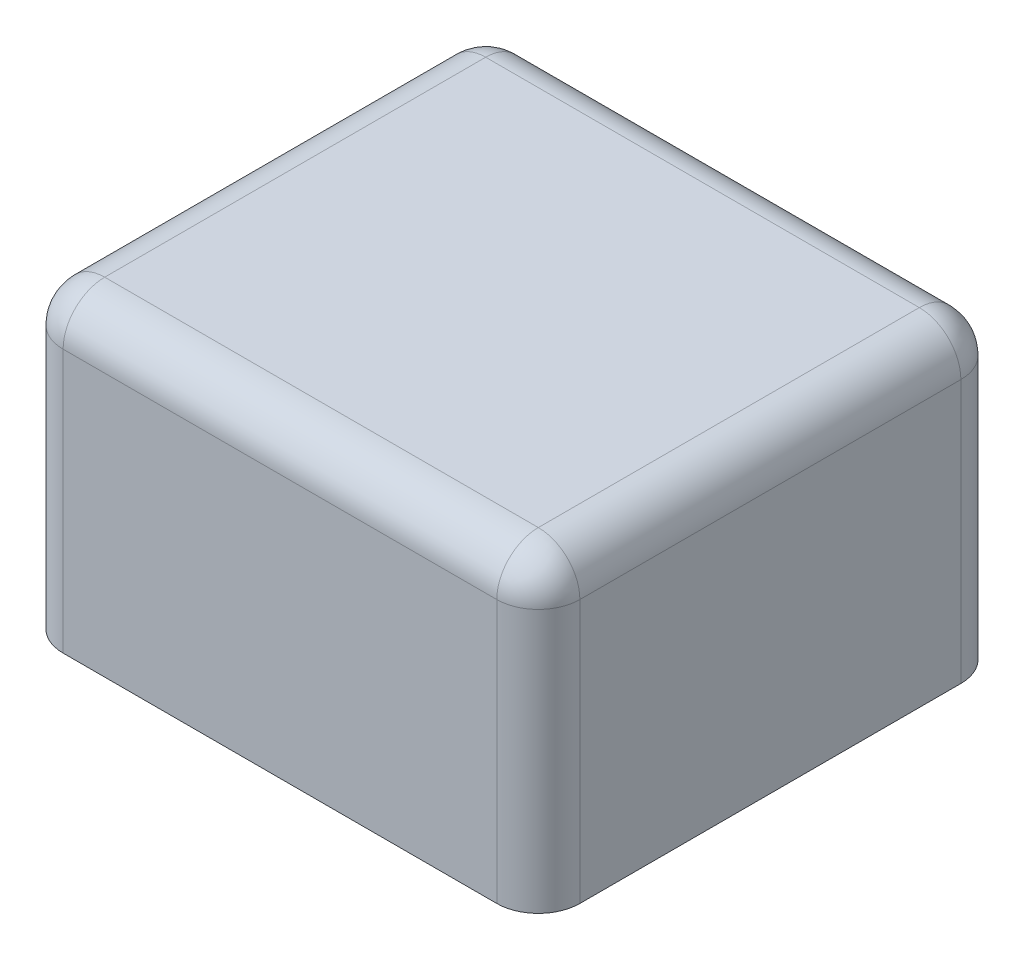
from build123d import *

# Parameters (mm, degrees)
CROQUIS1_W              = 37.3
CROQUIS1_H              = 33.5
SALIENTE_EXTRUIR1_DEPTH = 22
REDONDEO1_R             = 3


with BuildPart() as part:
    # Croquis1 → Saliente-Extruir1 (new body)
    with BuildSketch(Plane(origin=(0, 0, 0), x_dir=(1, 0, 0), z_dir=(0, 1, 0))):
        Rectangle(CROQUIS1_W, CROQUIS1_H)
    extrude(amount=SALIENTE_EXTRUIR1_DEPTH)

    # Redondeo1
    redondeo1_edges = [part.edges().sort_by_distance(p)[0] for p in [
        (-18.65, 22, 0),
        (0, 22, 16.75),
        (18.65, 22, 0),
        (0, 22, -16.75),
        (18.65, 11, 16.75),
        (-18.65, 11, 16.75),
        (-18.65, 11, -16.75),
        (18.65, 11, -16.75),
    ]]
    fillet(redondeo1_edges, radius=REDONDEO1_R)


solid = part.part
